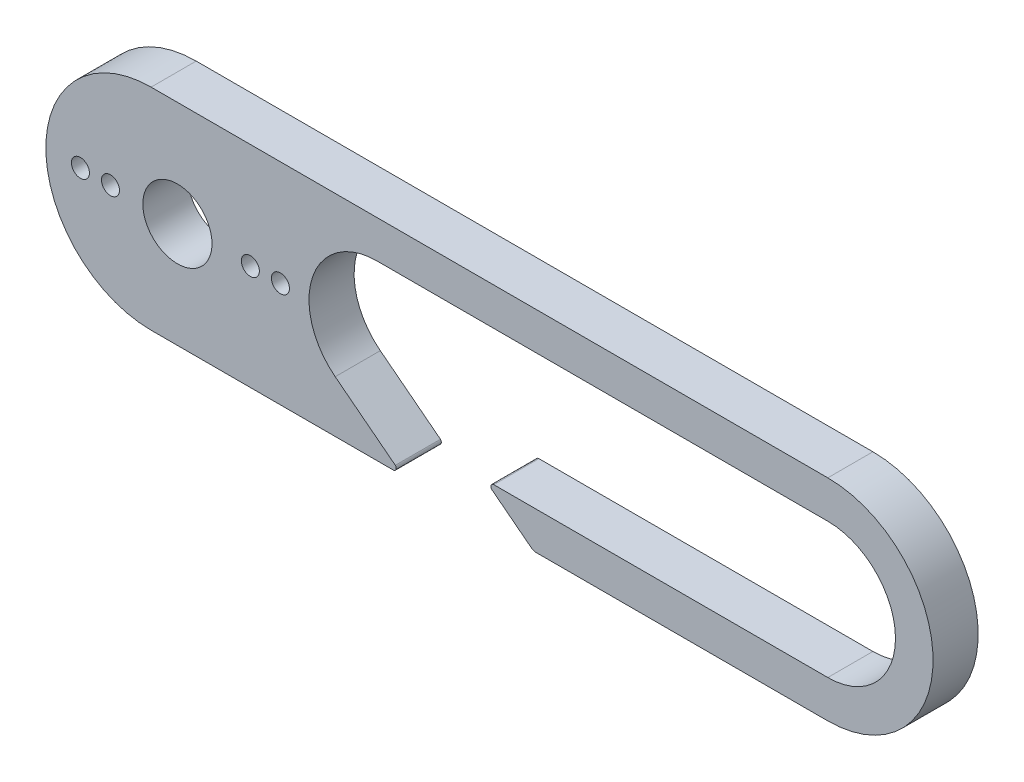
from build123d import *

# Parameters (mm, degrees)
SKETCH2_R           = 2.3
SKETCH2_R_2         = 0.6
BOSS_EXTRUDE1_DEPTH = 3


with BuildPart() as part:
    # Sketch2 → Boss-Extrude1 (new body)
    with BuildSketch(Plane.XY):
        with BuildLine():
            Line((16.770369268, 4.5), (46.770369268, 4.5))
            ThreePointArc((46.770369268, 4.5), (51.270370099, 0), (46.770369268, -4.5))
            Line((46.770369268, -4.5), (24.560820229, -4.5))
            ThreePointArc((24.560820229, -4.5), (24.371598614, -4.635229787), (24.438260986, -4.858048195))
            Line((24.438260986, -4.858048195), (27.065199516, -6.895120487))
            ThreePointArc((27.065199516, -6.895120487), (27.209672091, -6.973054037), (27.371597624, -7))
            Line((27.371597624, -7), (46.770368806, -7))
            ThreePointArc((46.770368806, -7), (53.770370099, -2.31e-07), (46.770369268, 7))
            Line((46.770369268, 7), (1.770370099, 7))
            ThreePointArc((1.770370099, 7), (-5.229629901, 0), (1.770370099, -7))
            Line((1.770370099, -7), (17.871597624, -7))
            ThreePointArc((17.871597624, -7), (18.057004855, -6.874994391), (18.010642647, -6.656241586))
            Line((18.010642647, -6.656241586), (14.012786293, -3.556084383))
            ThreePointArc((14.012786293, -3.556084383), (12.512882937, 1.457329797), (16.770369268, 4.5))
        make_face()
        with Locations((3.520369683, 0)):
            Circle(SKETCH2_R, mode=Mode.SUBTRACT)
        with Locations((8.370369683, 0)):
            Circle(SKETCH2_R_2, mode=Mode.SUBTRACT)
        with Locations((10.370369683, 0)):
            Circle(SKETCH2_R_2, mode=Mode.SUBTRACT)
        with Locations((-0.929630317, 0)):
            Circle(SKETCH2_R_2, mode=Mode.SUBTRACT)
        with Locations((-2.929630317, 0)):
            Circle(SKETCH2_R_2, mode=Mode.SUBTRACT)
    extrude(amount=BOSS_EXTRUDE1_DEPTH)


solid = part.part
